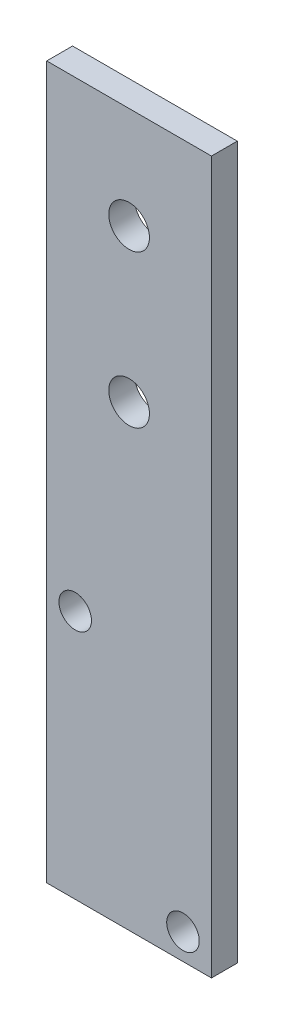
from build123d import *

# Parameters (mm, degrees)
SKETCH1_W           = 16.2
SKETCH1_H           = 70
BOSS_EXTRUDE1_DEPTH = 2.54
SKETCH4_R           = 1.6
CUT_EXTRUDE1_DEPTH  = 2.54
SKETCH6_R           = 2
CUT_EXTRUDE3_DEPTH  = 3.54


with BuildPart() as part:
    # Sketch1 → Boss-Extrude1 (new body)
    with BuildSketch(Plane.XY):
        with Locations((8.1, 35)):
            Rectangle(SKETCH1_W, SKETCH1_H)
    extrude(amount=BOSS_EXTRUDE1_DEPTH)

    # Sketch4 → Cut-Extrude1 (cut)
    with BuildSketch(Plane(origin=(0, 0, 0), x_dir=(-1, 0, 0), z_dir=(0, 0, -1))):
        with Locations((-13.4, 2.54)):
            Circle(SKETCH4_R)
        with Locations((-2.8, 24.54)):
            Circle(SKETCH4_R)
    extrude(amount=-CUT_EXTRUDE1_DEPTH, mode=Mode.SUBTRACT)

    # Sketch6 → Cut-Extrude3 (cut, through all)
    with BuildSketch(Plane.XY.offset(2.54)):
        with Locations((8.1, 60)):
            Circle(SKETCH6_R)
        with Locations((8.1, 45)):
            Circle(SKETCH6_R)
    extrude(amount=-CUT_EXTRUDE3_DEPTH, mode=Mode.SUBTRACT)


solid = part.part
